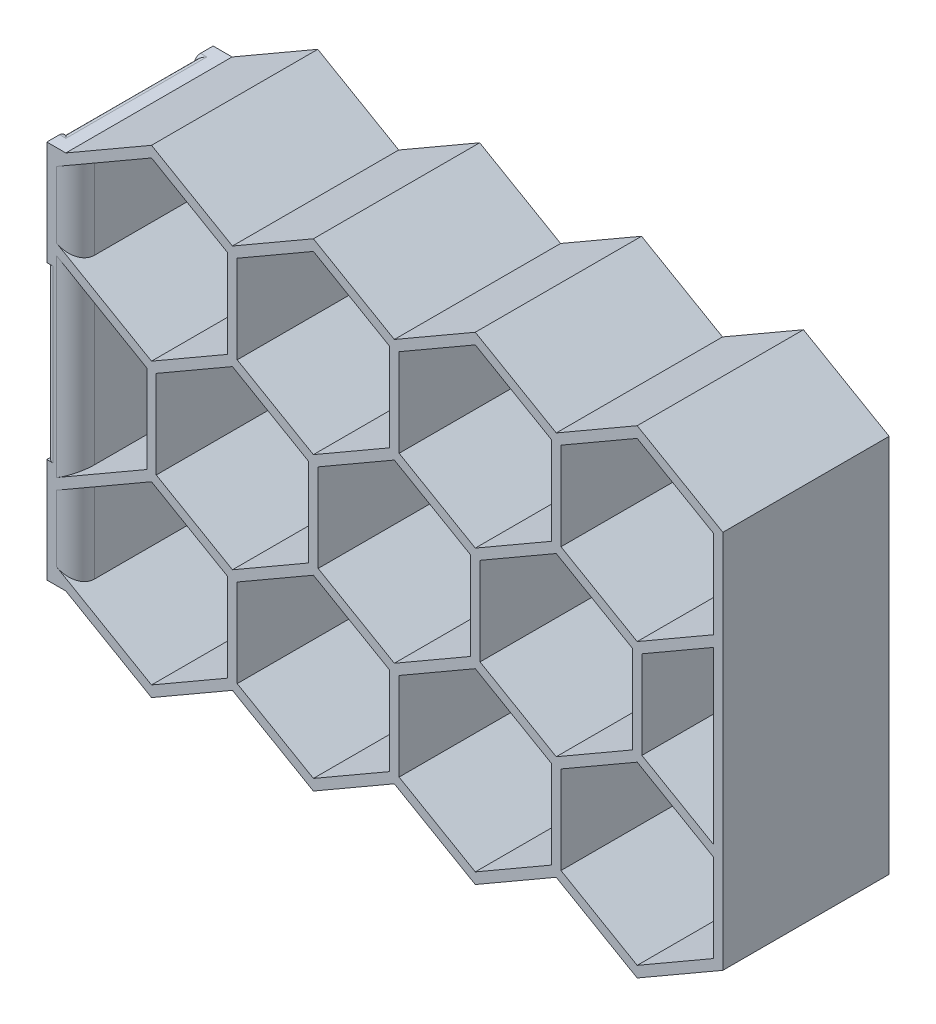
from build123d import *

# Parameters (mm, degrees)
SKETCH1_W                  = 26.3
SKETCH1_H                  = 26.3
SKETCH1_W_2                = 20.3
SKETCH1_H_2                = 20.3
TUBE_EXTRUDE_DEPTH         = 60
HEX_EXTRUDE_DEPTH          = 26.3
SKETCH3_W                  = 23.3
SKETCH3_H                  = 26.968911086
TUBE_CENTER_CUT_DEPTH      = 1
TUBE_CENTER_CUT_DEPTH_BACK = 27.3
CUT_EXTRUDE1_START         = -3
CUT_EXTRUDE1_DEPTH         = 3
SKETCH5_W                  = 1
SKETCH5_H                  = 10.515544457
CUT_EXTRUDE2_DEPTH         = 27.3
FILLET1_R                  = 3
FILLET2_R                  = 1
SKETCH6_W                  = 23.3
SKETCH6_H                  = 60
CUT_EXTRUDE3_DEPTH         = 27.3


with BuildPart() as part:
    # Sketch1 → Tube Extrude (new body)
    with BuildSketch(Plane(origin=(0, 0, 0), x_dir=(1, 0, 0), z_dir=(0, 1, 0))):
        with Locations((10.15, 10.15)):
            Rectangle(SKETCH1_W, SKETCH1_H)
        with Locations((10.15, 10.15)):
            Rectangle(SKETCH1_W_2, SKETCH1_H_2, mode=Mode.SUBTRACT)
    extrude(amount=TUBE_EXTRUDE_DEPTH)

    # Sketch2 → Hex Extrude (add)
    with BuildSketch(Plane.XY.offset(3)):
        Polygon((23.3, 15.649519053), (23.3, 0), (36.852881057, -7.824759526), (49.655762114, -0.433012702), (62.45864317, -7.824759526), (75.261524227, -0.433012702), (88.064405284, -7.824759526), (100.867286341, -0.433012702), (113.670167397, -7.824759526), (127.223048454, 0), (127.223048454, 15.649519053), (127.223048454, 44.350480947), (127.223048454, 60), (113.670167397, 67.824759526), (100.867286341, 60.433012702), (88.064405284, 67.824759526), (75.261524227, 60.433012702), (62.45864317, 67.824759526), (49.655762114, 60.433012702), (36.852881057, 67.824759526), (23.3, 60), (23.3, 44.350480947), align=None)
        Polygon((49.655762114, 16.082531755), (37.602881057, 23.041265877), (37.602881057, 36.958734123), (49.655762114, 43.917468245), (61.70864317, 36.958734123), (61.70864317, 23.041265877), align=None, mode=Mode.SUBTRACT)
        Polygon((36.102881057, 23.041265877), (24.8, 16.515544457), (24.8, 43.484455543), (36.102881057, 36.958734123), align=None, mode=Mode.SUBTRACT)
        Polygon((24.8, 0.866025404), (36.852881057, -6.092708719), (48.905762114, 0.866025404), (48.905762114, 14.783493649), (36.852881057, 21.742227772), (24.8, 14.783493649), align=None, mode=Mode.SUBTRACT)
        Polygon((50.405762114, 0.866025404), (62.45864317, -6.092708719), (74.511524227, 0.866025404), (74.511524227, 14.783493649), (62.45864317, 21.742227772), (50.405762114, 14.783493649), align=None, mode=Mode.SUBTRACT)
        Polygon((76.011524227, 0.866025404), (88.064405284, -6.092708719), (100.117286341, 0.866025404), (100.117286341, 14.783493649), (88.064405284, 21.742227772), (76.011524227, 14.783493649), align=None, mode=Mode.SUBTRACT)
        Polygon((125.723048454, 16.515544457), (114.420167397, 23.041265877), (114.420167397, 36.958734123), (125.723048454, 43.484455543), align=None, mode=Mode.SUBTRACT)
        Polygon((101.617286341, 0.866025404), (113.670167397, -6.092708719), (125.723048454, 0.866025404), (125.723048454, 14.783493649), (113.670167397, 21.742227772), (101.617286341, 14.783493649), align=None, mode=Mode.SUBTRACT)
        Polygon((24.8, 45.216506351), (36.852881057, 38.257772228), (48.905762114, 45.216506351), (48.905762114, 59.133974596), (36.852881057, 66.092708719), (24.8, 59.133974596), align=None, mode=Mode.SUBTRACT)
        Polygon((50.405762114, 45.216506351), (62.45864317, 38.257772228), (74.511524227, 45.216506351), (74.511524227, 59.133974596), (62.45864317, 66.092708719), (50.405762114, 59.133974596), align=None, mode=Mode.SUBTRACT)
        Polygon((76.011524227, 45.216506351), (88.064405284, 38.257772228), (100.117286341, 45.216506351), (100.117286341, 59.133974596), (88.064405284, 66.092708719), (76.011524227, 59.133974596), align=None, mode=Mode.SUBTRACT)
        Polygon((101.617286341, 45.216506351), (113.670167397, 38.257772228), (125.723048454, 45.216506351), (125.723048454, 59.133974596), (113.670167397, 66.092708719), (101.617286341, 59.133974596), align=None, mode=Mode.SUBTRACT)
        Polygon((75.261524227, 16.082531755), (87.314405284, 23.041265877), (87.314405284, 36.958734123), (75.261524227, 43.917468245), (63.20864317, 36.958734123), (63.20864317, 23.041265877), align=None, mode=Mode.SUBTRACT)
        Polygon((100.867286341, 16.082531755), (112.920167397, 23.041265877), (112.920167397, 36.958734123), (100.867286341, 43.917468245), (88.814405284, 36.958734123), (88.814405284, 23.041265877), align=None, mode=Mode.SUBTRACT)
    extrude(amount=-HEX_EXTRUDE_DEPTH)

    # Sketch3 → Tube Center Cut (cut, two sides)
    with BuildSketch(Plane.XY.offset(3)) as tube_center_cut_sk:
        with Locations((8.65, 30)):
            Rectangle(SKETCH3_W, SKETCH3_H)
    extrude(amount=TUBE_CENTER_CUT_DEPTH, mode=Mode.SUBTRACT)
    extrude(tube_center_cut_sk.sketch, amount=-TUBE_CENTER_CUT_DEPTH_BACK, mode=Mode.SUBTRACT)

    # Sketch4 → Cut-Extrude1 (cut)
    with BuildSketch(Plane.ZY.offset(3).offset(CUT_EXTRUDE1_START)):
        Polygon((-10.15, 60), (-10.35, 60), (-10.35, 0), (-10.15, 0), (-9.95, 0), (-9.95, 60), align=None)
    extrude(amount=CUT_EXTRUDE1_DEPTH, mode=Mode.SUBTRACT)

    # Sketch5 → Cut-Extrude2 (cut, through all)
    with BuildSketch(Plane.XY.offset(3)):
        with Locations((-2.5, 51.742227771)):
            Rectangle(SKETCH5_W, SKETCH5_H)
        with Locations((-2.5, 8.257772229)):
            Rectangle(SKETCH5_W, SKETCH5_H)
    extrude(amount=-CUT_EXTRUDE2_DEPTH, mode=Mode.SUBTRACT)

    # Fillet1
    fillet1_edges = [part.edges().sort_by_distance(p)[0] for p in [
        (-2, 51.742227772, -23.3),
        (-2, 51.742227772, 3),
        (-2, 8.257772228, -23.3),
        (-2, 8.257772228, 3),
        (24.8, 52.175240474, -23.3),
        (24.8, 52.175240474, 3),
        (24.8, 7.824759526, -23.3),
        (24.8, 7.824759526, 3),
        (24.8, 30, 3),
        (24.8, 30, -23.3),
    ]]
    fillet(fillet1_edges, radius=FILLET1_R)

    # Fillet2
    fillet2_edges = [part.edges().sort_by_distance(p)[0] for p in [
        (0, 0, -15.325),
        (10.15, 0, 0),
        (20.3, 0, -10.15),
        (10.15, 0, -20.3),
        (0, 60, -15.325),
        (10.15, 60, 0),
        (20.3, 60, -10.15),
        (10.15, 60, -20.3),
        (10.15, 43.484455543, -20.3),
        (10.15, 16.515544457, -20.3),
        (-3, 15.015544457, -23.3),
        (-3, 15.015544457, 3),
        (20.3, 30, 3),
        (10.15, 16.515544457, 0),
        (0, 16.515544457, -4.975),
        (0, 43.484455543, -15.325),
        (10.15, 43.484455543, 0),
        (20.3, 30, -23.3),
        (0, 43.484455543, -4.975),
        (0, 16.515544457, -15.325),
        (0, 60, -4.975),
        (0, 0, -4.975),
        (-3, 1.5, -23.3),
        (-3, 44.984455543, -23.3),
        (-3, 1.5, 3),
        (-3, 44.984455543, 3),
        (-3, 58.5, -23.3),
        (-3, 58.5, 3),
    ]]
    fillet(fillet2_edges, radius=FILLET2_R)

    # Sketch6 → Cut-Extrude3 (cut, through all)
    with BuildSketch(Plane.XY.offset(3)):
        with Locations((8.65, 30)):
            Rectangle(SKETCH6_W, SKETCH6_H)
    extrude(amount=-CUT_EXTRUDE3_DEPTH, mode=Mode.SUBTRACT)


solid = part.part
